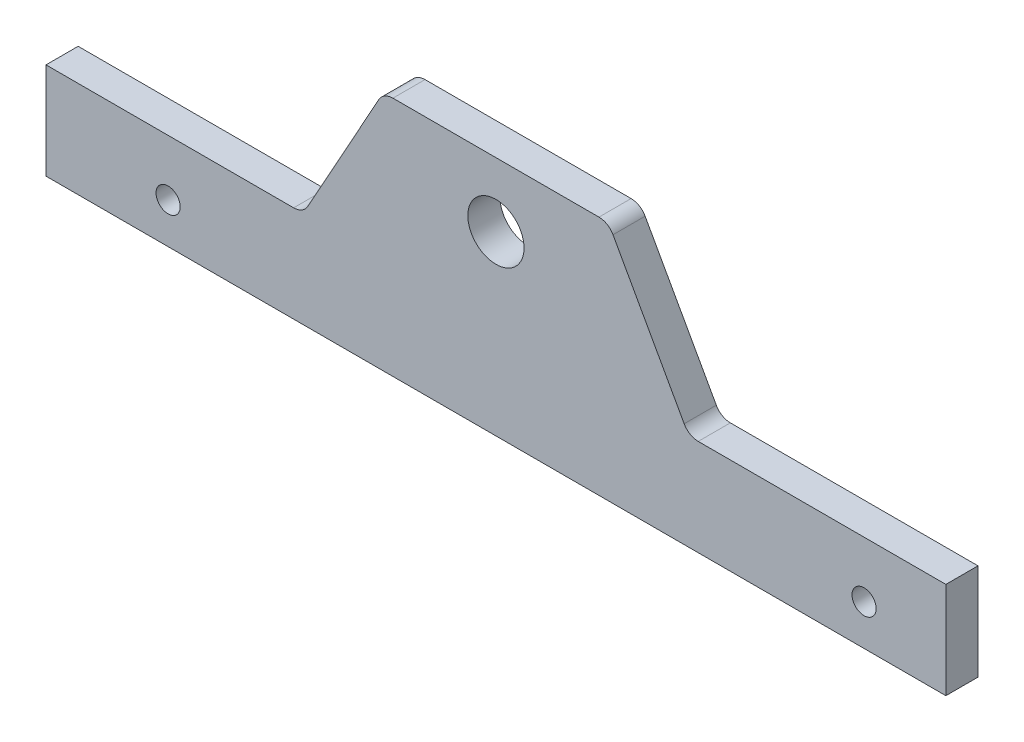
from build123d import *

# Parameters (mm, degrees)
SKETCH1_R           = 5.55625
BOSS_EXTRUDE1_DEPTH = 3.175
SKETCH2_R           = 2.3876
CUT_EXTRUDE1_DEPTH  = 7.35


with BuildPart() as part:
    # Sketch1 → Boss-Extrude1 (new body, symmetric)
    with BuildSketch(Plane.XY):
        with BuildLine():
            Line((-88.9, 0), (-39.968180633, 0))
            ThreePointArc((-39.968180633, 0), (-38.358050091, 0.438559861), (-37.192731281, 1.633083694))
            Line((-37.192731281, 1.633083694), (-23.132268719, 26.941916306))
            ThreePointArc((-23.132268719, 26.941916306), (-21.966949909, 28.136440139), (-20.356819367, 28.575))
            Line((-20.356819367, 28.575), (20.356819367, 28.575))
            ThreePointArc((20.356819367, 28.575), (21.966949909, 28.136440139), (23.132268719, 26.941916306))
            Line((23.132268719, 26.941916306), (37.192731281, 1.633083694))
            ThreePointArc((37.192731281, 1.633083694), (38.358050091, 0.438559861), (39.968180633, 0))
            Line((39.968180633, 0), (88.9, 0))
            Line((88.9, 0), (88.9, -19.05))
            Line((88.9, -19.05), (-88.9, -19.05))
            Line((-88.9, -19.05), (-88.9, 0))
        make_face()
        with Locations((0, 15.875)):
            Circle(SKETCH1_R, mode=Mode.SUBTRACT)
    extrude(amount=BOSS_EXTRUDE1_DEPTH, both=True)

    # Sketch2 → Cut-Extrude1 (cut, through all)
    with BuildSketch(Plane.XY.offset(3.175)):
        with Locations((-64.77, -11.049)):
            Circle(SKETCH2_R)
        with Locations((72.7456, -11.049)):
            Circle(SKETCH2_R)
    extrude(amount=-CUT_EXTRUDE1_DEPTH, mode=Mode.SUBTRACT)


solid = part.part
